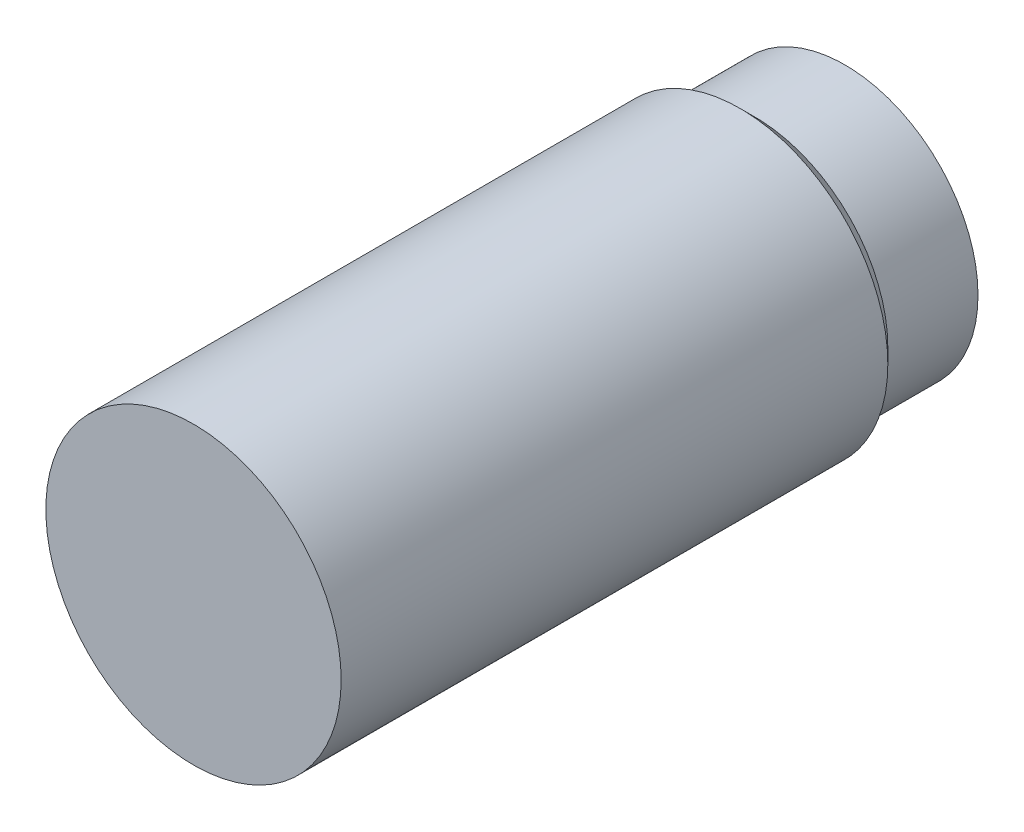
from build123d import *

# Parameters (mm, degrees)
SKETCH2_R          = 5.6
CUT_EXTRUDE1_DEPTH = 0.2


with BuildPart() as part:
    # Sketch1 → Revolve1 (revolve)
    with BuildSketch(Plane(origin=(0, 0, 0), x_dir=(0, 0, -1), z_dir=(1, 0, 0))):
        Polygon((0, 0), (0, 6.55), (24.25, 6.55), (24.9, 5.9), (28.9, 5.9), (28.9, 0), align=None)
    revolve(axis=Axis((0, 0, 0), (0, 0, -1)))

    # Sketch2 → Cut-Extrude1 (cut)
    with BuildSketch(Plane(origin=(0, 0, -28.9), x_dir=(-1, 0, 0), z_dir=(0, 0, -1))):
        Circle(SKETCH2_R)
    extrude(amount=-CUT_EXTRUDE1_DEPTH, mode=Mode.SUBTRACT)


solid = part.part
